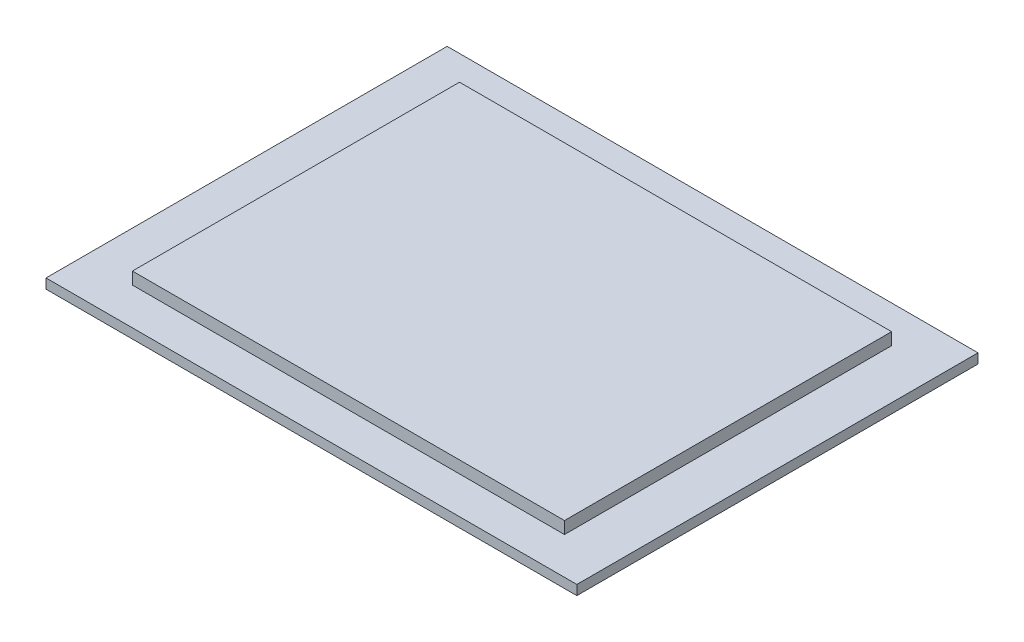
from build123d import *

# Parameters (mm, degrees)
SKETCH1_W      = 42.667
SKETCH1_H      = 32
EXTRUDE1_DEPTH = 0.3
SKETCH2_W      = 34.544
SKETCH2_H      = 25.908
EXTRUDE2_DEPTH = 1
SHELL1_T       = 0.5


with BuildPart() as part:
    # Sketch1 → Extrude1 (new body)
    with BuildSketch(Plane(origin=(0, 0, 0), x_dir=(1, 0, 0), z_dir=(0, 1, 0))):
        with Locations((21.3335, -16)):
            Rectangle(SKETCH1_W, SKETCH1_H)
    extrude(amount=EXTRUDE1_DEPTH)

    # Sketch2 → Extrude2 (add)
    with BuildSketch(Plane(origin=(0, 0.3, 0), x_dir=(-1, 0, 0), z_dir=(0, 1, 0))):
        with Locations((-21.3335, 16)):
            Rectangle(SKETCH2_W, SKETCH2_H)
    extrude(amount=EXTRUDE2_DEPTH)

    # Shell1
    shell1_openings = [part.faces().sort_by_distance(p)[0] for p in [
        (21.3335, 0, 16),
    ]]
    offset(amount=SHELL1_T, openings=shell1_openings, kind=Kind.INTERSECTION)


solid = part.part
